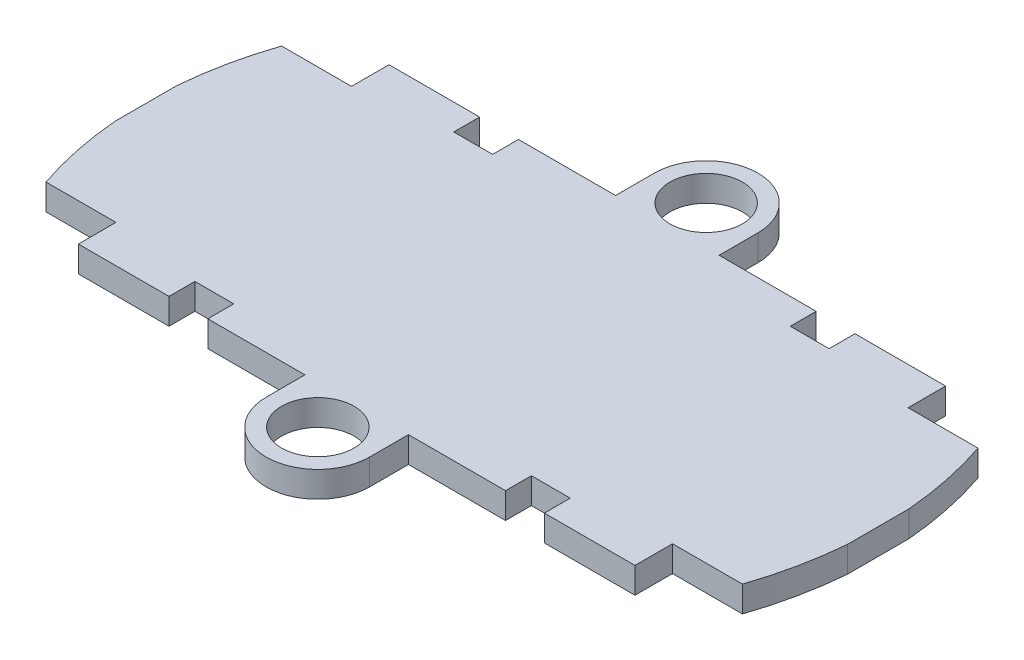
from build123d import *

# Parameters (mm, degrees)
SKETCH1_W               = 54.61
SKETCH1_H               = 23.114
SKETCH1_W_2             = 8.636
SKETCH1_H_2             = 3.683
BOSS_EXTRUDE1_DEPTH     = 2.54
CUT_EXTRUDE1_DEPTH      = 3.54
CUT_EXTRUDE1_DEPTH_BACK = 1
SKETCH3_R               = 3.556
BOSS_EXTRUDE2_DEPTH     = 2.54
SKETCH4_W               = 3.81
SKETCH4_H               = 2.54
CUT_EXTRUDE3_DEPTH      = 3.54


with BuildPart() as part:
    # Sketch1 → Boss-Extrude1 (new body)
    with BuildSketch(Plane(origin=(0, 0, 0), x_dir=(1, 0, 0), z_dir=(0, 1, 0))):
        Rectangle(SKETCH1_W, SKETCH1_H)
        with Locations((-31.623, 0)):
            Rectangle(SKETCH1_W_2, SKETCH1_H)
        with Locations((31.623, 0)):
            Rectangle(SKETCH1_W_2, SKETCH1_H)
        with Locations((0, -13.3985)):
            Rectangle(SKETCH1_W, SKETCH1_H_2)
        with Locations((0, 13.3985)):
            Rectangle(SKETCH1_W, SKETCH1_H_2)
    extrude(amount=BOSS_EXTRUDE1_DEPTH)

    # Sketch2 → Cut-Extrude1 (cut, two sides)
    with BuildSketch(Plane(origin=(0, 0, 0), x_dir=(1, 0, 0), z_dir=(0, 1, 0))) as cut_extrude1_sk:
        with BuildLine():
            Line((-36.068, 36.068), (-36.068, -3.1e-08))
            ThreePointArc((-36.068, -3.1e-08), (-25.503927395, 25.503927373), (0, 36.068))
            Line((0, 36.068), (-36.068, 36.068))
        make_face()
        with BuildLine():
            ThreePointArc((0, 36.068), (25.503927384, 25.503927384), (36.068, 0))
            Line((36.068, 0), (36.068, 36.068))
            Line((36.068, 36.068), (0, 36.068))
        make_face()
        with BuildLine():
            ThreePointArc((36.068, 0), (25.503927365, -25.503927403), (-5.3e-08, -36.068))
            Line((-5.3e-08, -36.068), (36.068, -36.068))
            Line((36.068, -36.068), (36.068, 0))
        make_face()
        with BuildLine():
            Line((-36.068, -3.1e-08), (-36.068, -36.068))
            Line((-36.068, -36.068), (-5.3e-08, -36.068))
            ThreePointArc((-5.3e-08, -36.068), (-25.503927391, -25.503927376), (-36.068, -3.1e-08))
        make_face()
    extrude(amount=CUT_EXTRUDE1_DEPTH, mode=Mode.SUBTRACT)
    extrude(cut_extrude1_sk.sketch, amount=-CUT_EXTRUDE1_DEPTH_BACK, mode=Mode.SUBTRACT)

    # Sketch3 → Boss-Extrude2 (add)
    with BuildSketch(Plane(origin=(0, 0, 0), x_dir=(1, 0, 0), z_dir=(0, 1, 0))):
        with BuildLine():
            Line((-5.08, 19.05), (-5.08, 15.24))
            Line((-5.08, 15.24), (5.08, 15.24))
            Line((5.08, 15.24), (5.08, 19.05))
            ThreePointArc((5.08, 19.05), (0, 24.13), (-5.08, 19.05))
        make_face()
        with Locations((0, 19.05)):
            Circle(SKETCH3_R, mode=Mode.SUBTRACT)
        with BuildLine():
            Line((-5.08, -19.05), (-5.08, -15.24))
            Line((-5.08, -15.24), (5.08, -15.24))
            Line((5.08, -15.24), (5.08, -19.05))
            ThreePointArc((5.08, -19.05), (0, -24.13), (-5.08, -19.05))
        make_face()
        with Locations((0, -19.05)):
            Circle(SKETCH3_R, mode=Mode.SUBTRACT)
    extrude(amount=BOSS_EXTRUDE2_DEPTH)

    # Sketch4 → Cut-Extrude3 (cut, through all)
    with BuildSketch(Plane(origin=(0, 0, 0), x_dir=(1, 0, 0), z_dir=(0, 1, 0))):
        with Locations((-16.51, 13.97)):
            Rectangle(SKETCH4_W, SKETCH4_H)
        with Locations((16.51, 13.97)):
            Rectangle(SKETCH4_W, SKETCH4_H)
        with Locations((-16.51, -13.97)):
            Rectangle(SKETCH4_W, SKETCH4_H)
        with Locations((16.51, -13.97)):
            Rectangle(SKETCH4_W, SKETCH4_H)
    extrude(amount=CUT_EXTRUDE3_DEPTH, mode=Mode.SUBTRACT)


solid = part.part
